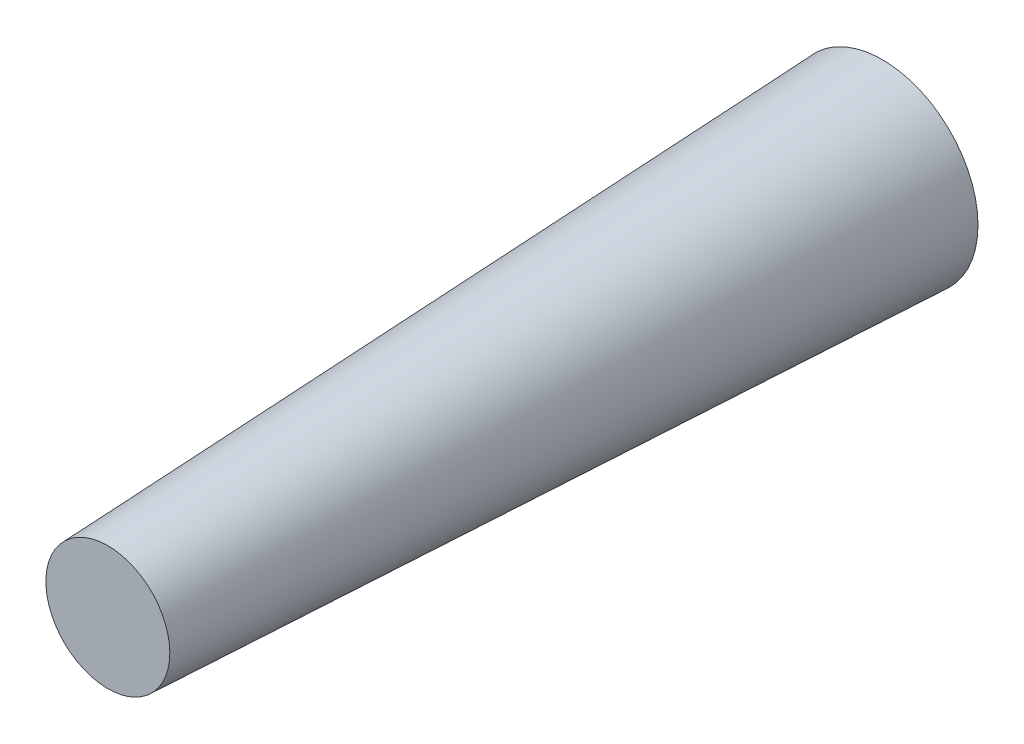
from build123d import *

# Parameters (mm, degrees)
SKETCH1_R = 18.5
SKETCH2_R = 12


with BuildPart() as part:
    # Sketch1 → Loft1 section 0
    with BuildSketch(Plane.XY):
        Circle(SKETCH1_R)
    # Sketch2 → Loft1 section 1
    with BuildSketch(Plane.XY.offset(150)):
        Circle(SKETCH2_R)
    loft()


solid = part.part
